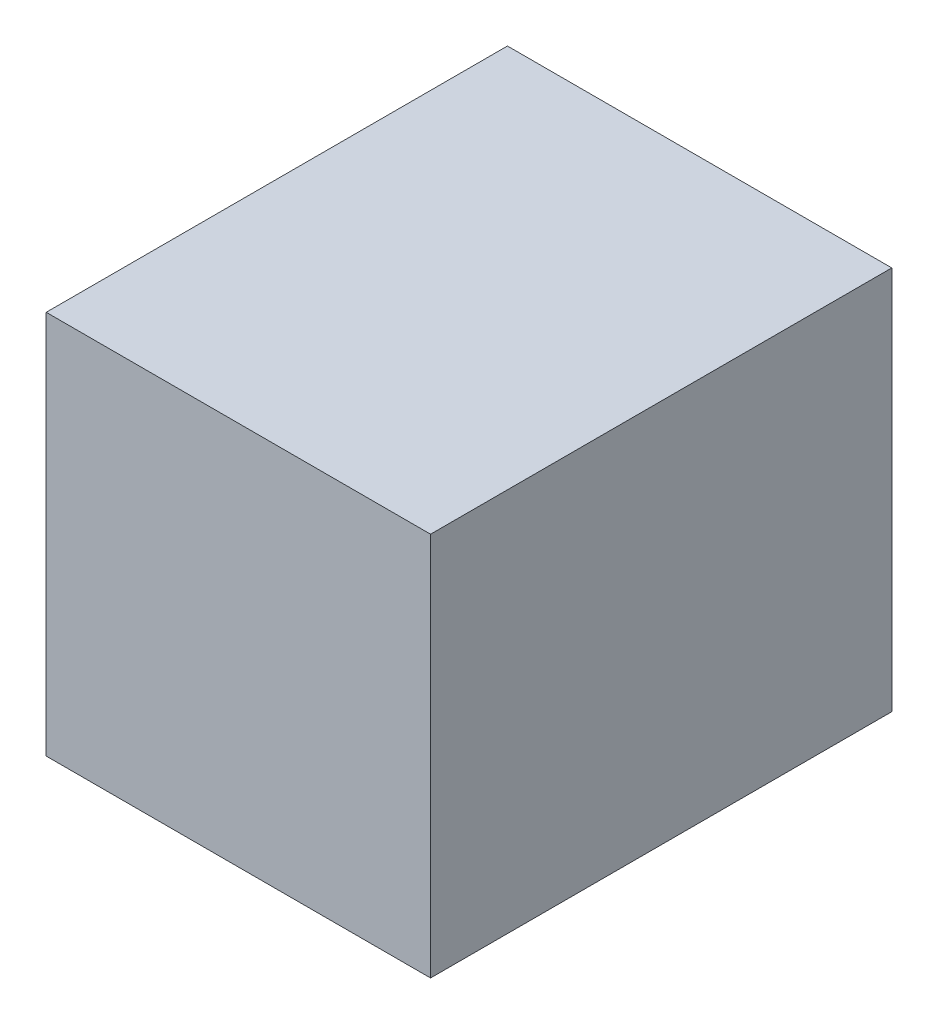
from build123d import *

# Parameters (mm, degrees)
SKETCH1_W           = 9.525
SKETCH1_H           = 9.525
BOSS_EXTRUDE1_DEPTH = 11.43


with BuildPart() as part:
    # Sketch1 → Boss-Extrude1 (new body)
    with BuildSketch(Plane.XY):
        with Locations((4.7625, 4.7625)):
            Rectangle(SKETCH1_W, SKETCH1_H)
    extrude(amount=BOSS_EXTRUDE1_DEPTH)


solid = part.part
